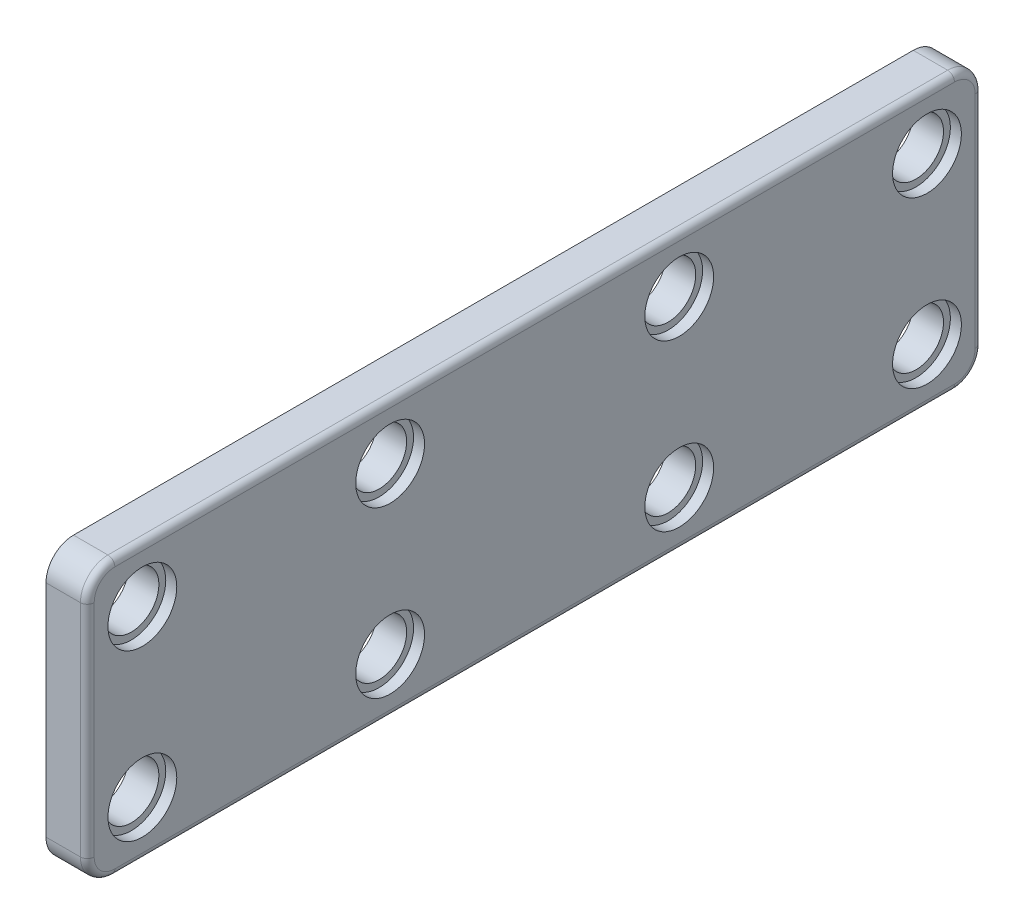
from build123d import *

# Parameters (mm, degrees)
SKETCH2_W            = 3
SKETCH2_H            = 20
BOSS_EXTRUDE2_DEPTH  = 65
FILLET3_R            = 2
FILLET4_R            = 2
FILLET5_R            = 2
FILLET6_R            = 2
LPATTERN1_COUNT      = 2
LPATTERN1_PITCH      = 18
LPATTERN1_COUNT_DIR2 = 2
LPATTERN1_PITCH_DIR2 = 12
FILLET7_R            = 0.5


with BuildPart() as part:
    # Sketch2 → Boss-Extrude2 (new body)
    with BuildSketch(Plane.XY):
        Rectangle(SKETCH2_W, SKETCH2_H)
    extrude(amount=BOSS_EXTRUDE2_DEPTH)

    # Fillet3
    fillet3_edges = [part.edges().sort_by_distance(p)[0] for p in [
        (0, 10, 65),
    ]]
    fillet(fillet3_edges, radius=FILLET3_R)

    # Fillet4
    fillet4_edges = [part.edges().sort_by_distance(p)[0] for p in [
        (0, -10, 65),
    ]]
    fillet(fillet4_edges, radius=FILLET4_R)

    # Fillet5
    fillet5_edges = [part.edges().sort_by_distance(p)[0] for p in [
        (0, 10, 0),
    ]]
    fillet(fillet5_edges, radius=FILLET5_R)

    # Fillet6
    fillet6_edges = [part.edges().sort_by_distance(p)[0] for p in [
        (0, -10, 0),
    ]]
    fillet(fillet6_edges, radius=FILLET6_R)

    # Sketch4 → CBORE for M5 Hex Head Bolt1 (revolve, cut)
    with BuildSketch(Plane(origin=(1.5, 6, 61), x_dir=(0, 0, -1), z_dir=(0, 1, 0))):
        Polygon((0, 0), (0, 5.178090033), (2, 4), (2, 0.8), (2.5, 0.8), (2.5, 0), align=None)
    cbore_for_m5_hex_head_bolt1 = revolve(axis=Axis((7.85, 6, 61), (-1, 0, 0)), mode=Mode.SUBTRACT)

    # LPattern1: CBORE for M5 Hex Head Bolt1 2 × 2
    with Locations(*[(0, -j * LPATTERN1_PITCH_DIR2, -i * LPATTERN1_PITCH) for i in range(LPATTERN1_COUNT) for j in range(LPATTERN1_COUNT_DIR2) if (i, j) != (0, 0)]):
        add(cbore_for_m5_hex_head_bolt1, mode=Mode.SUBTRACT)

    # Mirror16: CBORE for M5 Hex Head Bolt1 across plane
    add(cbore_for_m5_hex_head_bolt1.mirror(Plane.XY.offset(32.5)), mode=Mode.SUBTRACT)

    # Mirror16 copy 1 sketch → Mirror16 copy 1 (revolve, cut)
    with BuildSketch(Plane(origin=(1.5, -6, 4), x_dir=(0, 0, 1), z_dir=(0, 1, 0))):
        Polygon((0, 0), (0, -5.178090033), (2, -4), (2, -0.8), (2.5, -0.8), (2.5, 0), align=None)
    revolve(axis=Axis((7.85, -6, 4), (1, 0, 0)), mode=Mode.SUBTRACT)

    # Mirror16 copy 2 sketch → Mirror16 copy 2 (revolve, cut)
    with BuildSketch(Plane(origin=(1.5, 6, 22), x_dir=(0, 0, 1), z_dir=(0, 1, 0))):
        Polygon((0, 0), (0, -5.178090033), (2, -4), (2, -0.8), (2.5, -0.8), (2.5, 0), align=None)
    revolve(axis=Axis((7.85, 6, 22), (1, 0, 0)), mode=Mode.SUBTRACT)

    # Mirror16 copy 3 sketch → Mirror16 copy 3 (revolve, cut)
    with BuildSketch(Plane(origin=(1.5, -6, 22), x_dir=(0, 0, 1), z_dir=(0, 1, 0))):
        Polygon((0, 0), (0, -5.178090033), (2, -4), (2, -0.8), (2.5, -0.8), (2.5, 0), align=None)
    revolve(axis=Axis((7.85, -6, 22), (1, 0, 0)), mode=Mode.SUBTRACT)

    # Fillet7
    fillet7_edges = [part.edges().sort_by_distance(p)[0] for p in [
        (1.5, 10, 32.5),
        (1.5, 9.414213562, 64.414213562),
        (1.5, 0, 65),
        (1.5, -10, 32.5),
        (1.5, -9.414213562, 64.414213562),
        (1.5, 9.414213562, 0.585786438),
        (1.5, 0, 0),
        (1.5, -9.414213562, 0.585786438),
    ]]
    fillet(fillet7_edges, radius=FILLET7_R)


solid = part.part
